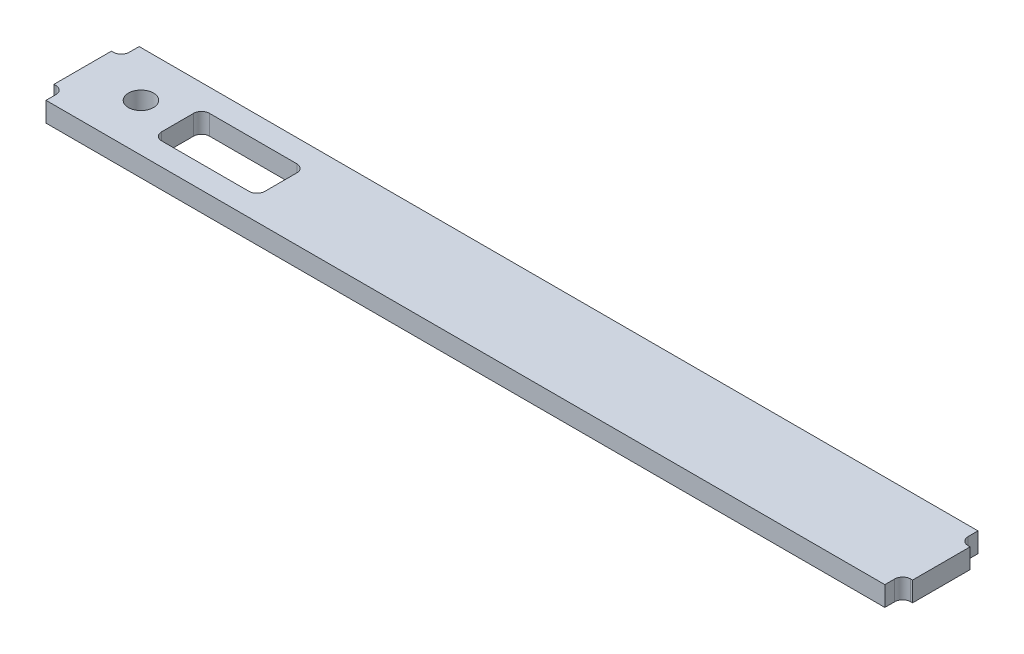
from build123d import *

# Parameters (mm, degrees)
SKETCH1_W               = 673.1
SKETCH1_H               = 74.742799968
BOSS_EXTRUDE1_DEPTH     = 15.875
SKETCH3_R               = 10.1
CUT_EXTRUDE1_DEPTH      = 1
CUT_EXTRUDE1_DEPTH_BACK = 16.875
SKETCH4_W               = 7.9375
SKETCH4_H               = 46.167799968
BOSS_EXTRUDE3_DEPTH     = 15.875
FILLET2_R               = 6.35
SKETCH5_W               = 82.804
SKETCH5_H               = 38.354
CUT_EXTRUDE2_DEPTH      = 1
CUT_EXTRUDE2_DEPTH_BACK = 16.875
FILLET3_R               = 6.35


with BuildPart() as part:
    # Sketch1 → Boss-Extrude1 (new body)
    with BuildSketch(Plane(origin=(0, 0, 0), x_dir=(1, 0, 0), z_dir=(0, 1, 0))):
        Rectangle(SKETCH1_W, SKETCH1_H)
    extrude(amount=BOSS_EXTRUDE1_DEPTH)

    # Sketch3 → Cut-Extrude1 (cut, two sides)
    with BuildSketch(Plane(origin=(0, 15.875, 0), x_dir=(1, 0, 0), z_dir=(0, 1, 0))) as cut_extrude1_sk:
        with Locations((-298.45, 0.728600016)):
            Circle(SKETCH3_R)
    extrude(amount=CUT_EXTRUDE1_DEPTH, mode=Mode.SUBTRACT)
    extrude(cut_extrude1_sk.sketch, amount=-CUT_EXTRUDE1_DEPTH_BACK, mode=Mode.SUBTRACT)

    # Sketch4 → Boss-Extrude3 (add)
    with BuildSketch(Plane(origin=(0, 15.875, 0), x_dir=(1, 0, 0), z_dir=(0, 1, 0))):
        with Locations((-340.51875, 0)):
            Rectangle(SKETCH4_W, SKETCH4_H)
        with Locations((340.51875, 0)):
            Rectangle(SKETCH4_W, SKETCH4_H)
    extrude(amount=-BOSS_EXTRUDE3_DEPTH)

    # Fillet2
    fillet2_edges = [part.edges().sort_by_distance(p)[0] for p in [
        (-336.55, 7.9375, 23.083899984),
        (-336.55, 7.9375, -23.083899984),
        (336.55, 7.9375, 23.083899984),
        (336.55, 7.9375, -23.083899984),
    ]]
    fillet(fillet2_edges, radius=FILLET2_R)

    # Sketch5 → Cut-Extrude2 (cut, two sides)
    with BuildSketch(Plane(origin=(0, 15.875, 0), x_dir=(1, 0, 0), z_dir=(0, 1, 0))) as cut_extrude2_sk:
        with Locations((-226.8855, 0)):
            Rectangle(SKETCH5_W, SKETCH5_H)
    extrude(amount=CUT_EXTRUDE2_DEPTH, mode=Mode.SUBTRACT)
    extrude(cut_extrude2_sk.sketch, amount=-CUT_EXTRUDE2_DEPTH_BACK, mode=Mode.SUBTRACT)

    # Fillet3
    fillet3_edges = [part.edges().sort_by_distance(p)[0] for p in [
        (-268.2875, 7.9375, 19.177),
        (-268.2875, 7.9375, -19.177),
        (-185.4835, 7.9375, -19.177),
        (-185.4835, 7.9375, 19.177),
    ]]
    fillet(fillet3_edges, radius=FILLET3_R)


solid = part.part
